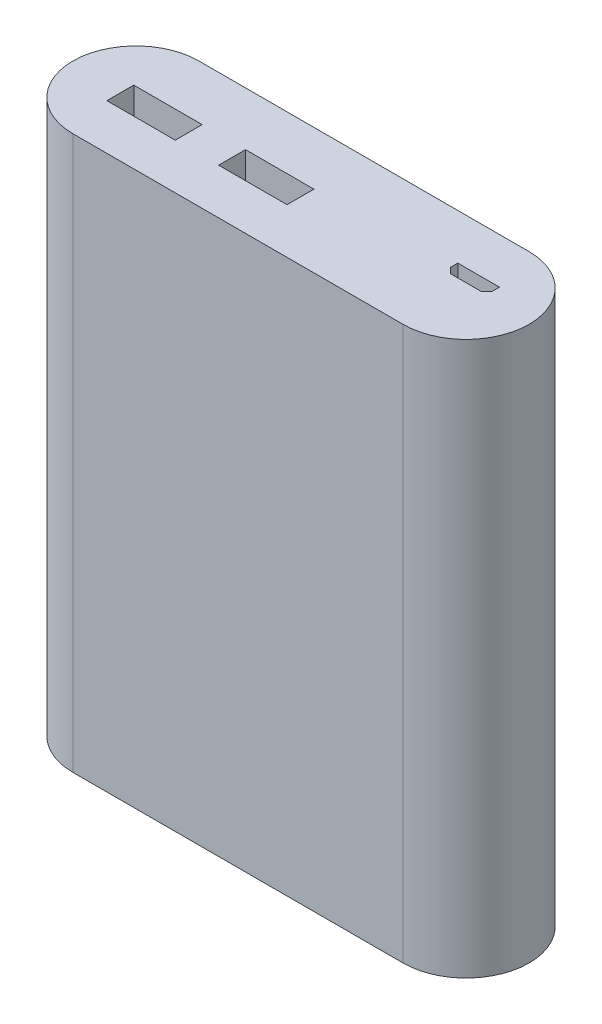
from build123d import *

# Parameters (mm, degrees)
BOSS_EXTRUDE1_DEPTH = 97
SKETCH2_W           = 12
SKETCH2_H           = 4.72
CUT_EXTRUDE1_DEPTH  = 10


with BuildPart() as part:
    # Sketch1 → Boss-Extrude1 (new body)
    with BuildSketch(Plane(origin=(0, 0, 0), x_dir=(1, 0, 0), z_dir=(0, 1, 0))):
        with BuildLine():
            Line((-28.95, 11.05), (28.95, 11.05))
            ThreePointArc((28.95, 11.05), (40, 0), (28.95, -11.05))
            Line((28.95, -11.05), (-28.95, -11.05))
            ThreePointArc((-28.95, -11.05), (-40, 0), (-28.95, 11.05))
        make_face()
    extrude(amount=BOSS_EXTRUDE1_DEPTH)

    # Sketch2 → Cut-Extrude1 (cut)
    with BuildSketch(Plane(origin=(0, 97, 0), x_dir=(1, 0, 0), z_dir=(0, 1, 0))):
        with Locations((-25, -0.69)):
            Rectangle(SKETCH2_W, SKETCH2_H)
        with Locations((-5.4, -0.69)):
            Rectangle(SKETCH2_W, SKETCH2_H)
        Polygon((25.45, 0.8), (24.45, 1.8), (24.45, 3.05), (31.75, 3.05), (31.75, 1.8), (30.75, 0.8), align=None)
    extrude(amount=-CUT_EXTRUDE1_DEPTH, mode=Mode.SUBTRACT)


solid = part.part
